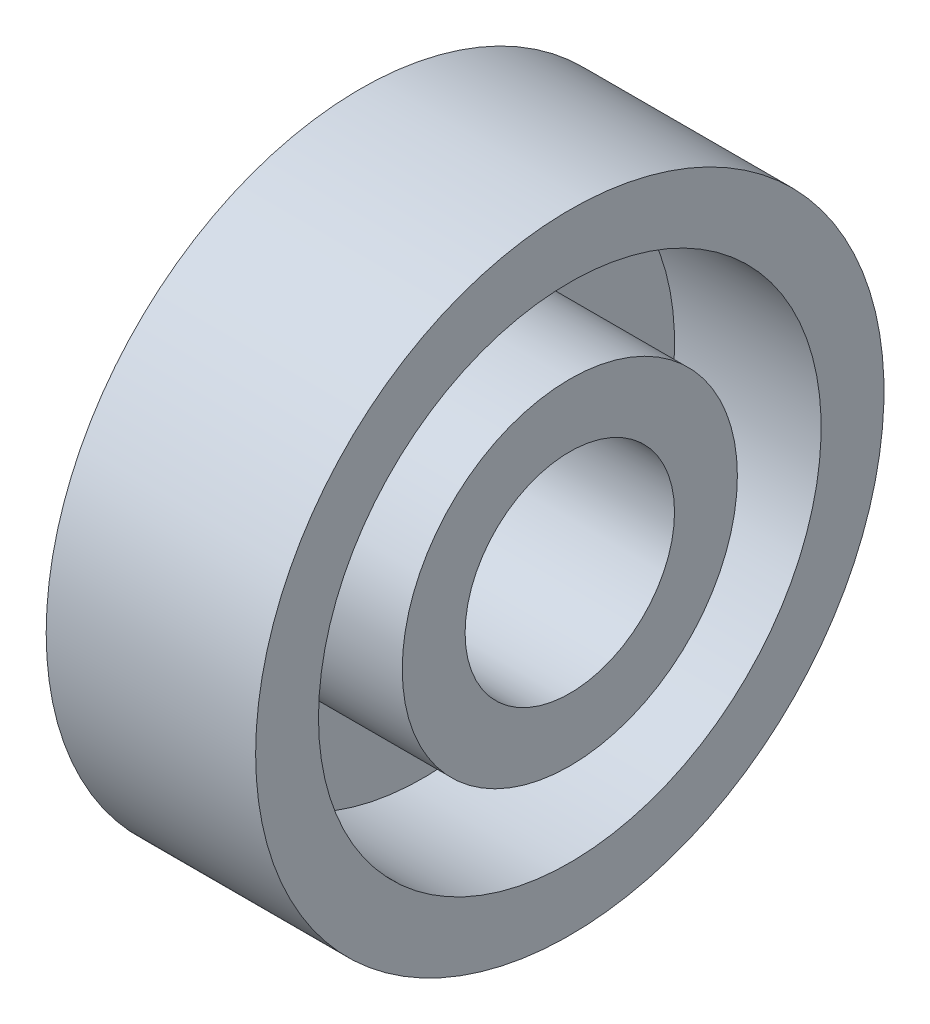
from build123d import *


with BuildPart() as part:
    # Skizze1 → Rotation1 (revolve)
    with BuildSketch(Plane.XY):
        Polygon((4, 2), (0, 2), (0, 6), (4, 6), (4, 4.8), (1.2, 4.8), (1.2, 3.2), (4, 3.2), align=None)
    revolve(axis=Axis((0, 0, 0), (1, 0, 0)))


solid = part.part
